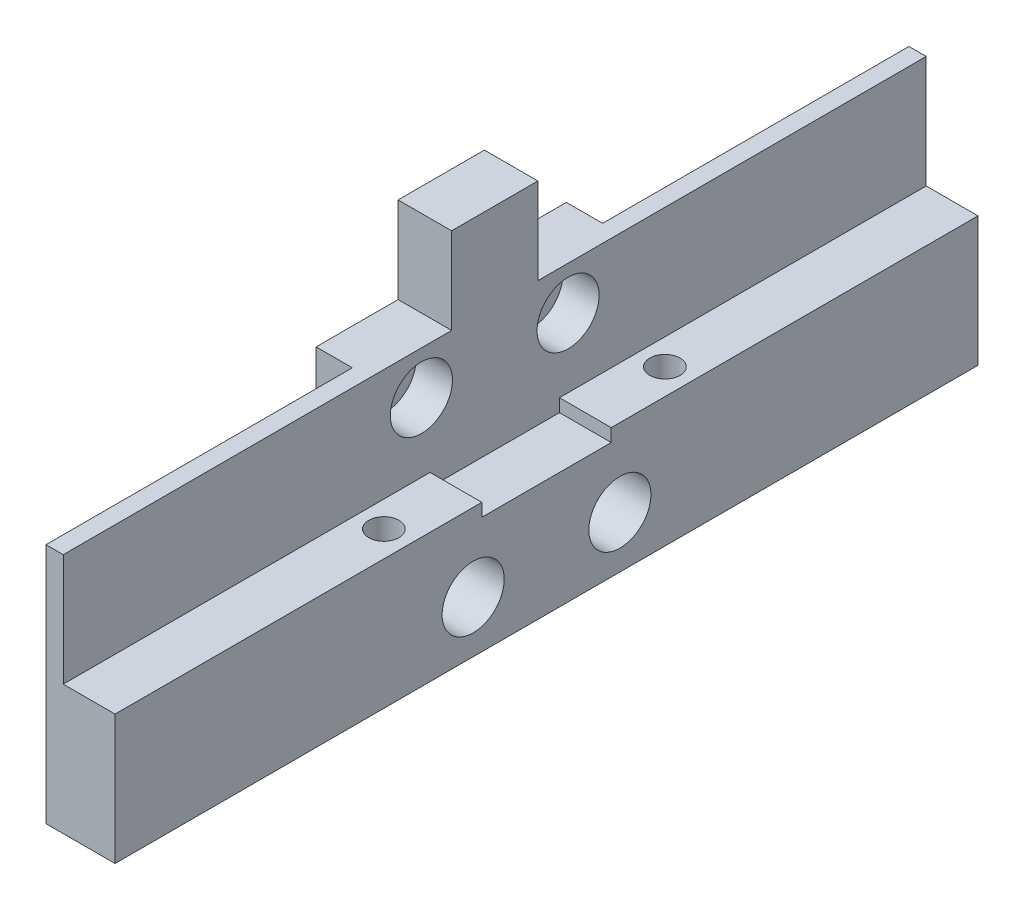
from build123d import *

# Parameters (mm, degrees)
SKETCH1_W               = 100
SKETCH1_H               = 26
BOSS_EXTRUDE1_DEPTH     = 2
BOSS_EXTRUDE2_DEPTH     = 100
SKETCH3_W               = 25
SKETCH3_H               = 28
BOSS_EXTRUDE3_DEPTH     = 4
SKETCH4_R               = 2.1
CUT_EXTRUDE1_DEPTH      = 106.39449701
SKETCH5_W               = 120
SKETCH5_H               = 46
SKETCH5_W_2             = 100
SKETCH5_H_2             = 26
CUT_EXTRUDE2_DEPTH      = 105.537074763
CUT_EXTRUDE2_DEPTH_BACK = 105.537074763
SKETCH6_W               = 100
SKETCH6_H               = 26
SKETCH6_R               = 3.6
BOSS_EXTRUDE4_DEPTH     = 4.2
SKETCH8_W               = 100
SKETCH8_H               = 4
BOSS_EXTRUDE5_DEPTH     = 6
SKETCH9_W               = 100
SKETCH9_H               = 4
BOSS_EXTRUDE6_DEPTH     = 10.2
SKETCH10_W              = 4
SKETCH10_H              = 37.5
CUT_EXTRUDE3_DEPTH      = 106.682732743
SKETCH11_W              = 4
SKETCH11_H              = 25
CUT_EXTRUDE4_DEPTH      = 107.737247482
SKETCH13_W              = 10
SKETCH13_H              = 10
BOSS_EXTRUDE7_DEPTH     = 6.2
SKETCH14_W              = 4.2
SKETCH14_H              = 35.5
CUT_EXTRUDE5_DEPTH      = 107.737247482
SKETCH15_R              = 3.6
BOSS_EXTRUDE8_DEPTH     = 6
SKETCH17_R              = 1.75
CUT_EXTRUDE7_DEPTH      = 105.984951303
MOVE_FACE2_BY           = 2


with BuildPart() as part:
    # Sketch1 → Boss-Extrude1 (new body)
    with BuildSketch(Plane(origin=(0, 0, 0), x_dir=(0, 0, -1), z_dir=(1, 0, 0))):
        with Locations((50, 13)):
            Rectangle(SKETCH1_W, SKETCH1_H)
    extrude(amount=BOSS_EXTRUDE1_DEPTH)

    # Sketch2 → Boss-Extrude2 (add)
    with BuildSketch(Plane.XY):
        Polygon((2, 26), (2, 28), (-12, 28), (-12, 24), (-10, 24), (-10, 26), align=None)
    extrude(amount=-BOSS_EXTRUDE2_DEPTH)

    # Sketch3 → Boss-Extrude3 (add)
    with BuildSketch(Plane(origin=(2, 0, 0), x_dir=(0, 0, -1), z_dir=(1, 0, 0))):
        with Locations((50, 14)):
            Rectangle(SKETCH3_W, SKETCH3_H)
    extrude(amount=BOSS_EXTRUDE3_DEPTH)

    # Sketch4 → Cut-Extrude1 (cut, through all)
    with BuildSketch(Plane(origin=(6, 0, 0), x_dir=(0, 0, -1), z_dir=(1, 0, 0))):
        with Locations((41.5, 21)):
            Circle(SKETCH4_R)
        with Locations((58.5, 21)):
            Circle(SKETCH4_R)
        with Locations((58.5, 4)):
            Circle(SKETCH4_R)
        with Locations((41.5, 4)):
            Circle(SKETCH4_R)
    extrude(amount=-CUT_EXTRUDE1_DEPTH, mode=Mode.SUBTRACT)


with BuildPart() as body_2:
    # Mirror1: mirrored copy
    add(part.part.mirror(Plane(origin=(6, 0, 0), x_dir=(0, 0, 1), z_dir=(1, 0, 0))))

    # Sketch5 → Cut-Extrude2 (cut, two sides)
    with BuildSketch(Plane(origin=(12, 0, 0), x_dir=(0, 0, -1), z_dir=(1, 0, 0))) as cut_extrude2_sk:
        with Locations((50, 13)):
            Rectangle(SKETCH5_W, SKETCH5_H)
        with Locations((50, 13)):
            Rectangle(SKETCH5_W_2, SKETCH5_H_2, mode=Mode.SUBTRACT)
    extrude(amount=CUT_EXTRUDE2_DEPTH, mode=Mode.SUBTRACT)
    extrude(cut_extrude2_sk.sketch, amount=-CUT_EXTRUDE2_DEPTH_BACK, mode=Mode.SUBTRACT)


with BuildPart() as body_2_2:
    # of the pieces the cut leaves, the one that is kept (cut_extrude2_keep)
    add(body_2.part.solids().sort_by_distance((12, 0, 0))[0])

    # Sketch6 → Boss-Extrude4 (add)
    with BuildSketch(Plane(origin=(12, 0, 0), x_dir=(0, 0, -1), z_dir=(1, 0, 0))):
        with Locations((50, 13)):
            Rectangle(SKETCH6_W, SKETCH6_H)
        with Locations((41.5, 21)):
            Circle(SKETCH6_R, mode=Mode.SUBTRACT)
        with Locations((58.5, 21)):
            Circle(SKETCH6_R, mode=Mode.SUBTRACT)
        with Locations((58.5, 4)):
            Circle(SKETCH6_R, mode=Mode.SUBTRACT)
        with Locations((41.5, 4)):
            Circle(SKETCH6_R, mode=Mode.SUBTRACT)
    extrude(amount=BOSS_EXTRUDE4_DEPTH)



with BuildPart() as body_2_3:
    # Sketch8 → Boss-Extrude5 (new body)
    with BuildSketch(Plane(origin=(16.2, 0, 0), x_dir=(0, 0, -1), z_dir=(1, 0, 0))):
        with Locations((50, -2)):
            Rectangle(SKETCH8_W, SKETCH8_H)
    extrude(amount=BOSS_EXTRUDE5_DEPTH)


with BuildPart() as body_2_2_1:
    add(body_2_2.part)

    add(body_2_3.part)  # Boss-Extrude6 merges body 2 3
    # Sketch9 → Boss-Extrude6 (add)
    with BuildSketch(Plane.ZY.offset(-16.2)):
        with Locations((-50, -2)):
            Rectangle(SKETCH9_W, SKETCH9_H)
    extrude(amount=BOSS_EXTRUDE6_DEPTH)

    # Sketch10 → Cut-Extrude3 (cut, through all)
    with BuildSketch(Plane(origin=(0, 0, 0), x_dir=(1, 0, 0), z_dir=(0, 1, 0))):
        with Locations((8, 81.25)):
            Rectangle(SKETCH10_W, SKETCH10_H)
        with Locations((8, 18.75)):
            Rectangle(SKETCH10_W, SKETCH10_H)
    extrude(amount=-CUT_EXTRUDE3_DEPTH, mode=Mode.SUBTRACT)

    # Sketch11 → Cut-Extrude4 (cut, through all)
    with BuildSketch(Plane(origin=(0, 26, 0), x_dir=(1, 0, 0), z_dir=(0, 1, 0))):
        with Locations((8, 50)):
            Rectangle(SKETCH11_W, SKETCH11_H)
    extrude(amount=-CUT_EXTRUDE4_DEPTH, mode=Mode.SUBTRACT)

    # Sketch13 → Boss-Extrude7 (add)
    with BuildSketch(Plane.ZY.offset(-10)):
        with Locations((-50, 31)):
            Rectangle(SKETCH13_W, SKETCH13_H)
    extrude(amount=-BOSS_EXTRUDE7_DEPTH)

    # Sketch14 → Cut-Extrude5 (cut, through all)
    with BuildSketch(Plane(origin=(0, 26, 0), x_dir=(1, 0, 0), z_dir=(0, 1, 0))):
        with Locations((12.1, 17.75)):
            Rectangle(SKETCH14_W, SKETCH14_H)
        with Locations((12.1, 82.25)):
            Rectangle(SKETCH14_W, SKETCH14_H)
    extrude(amount=-CUT_EXTRUDE5_DEPTH, mode=Mode.SUBTRACT)

    # Sketch15 → Boss-Extrude8 (add)
    with BuildSketch(Plane(origin=(22.2, 0, 0), x_dir=(0, 0, -1), z_dir=(1, 0, 0))):
        Polygon((0, 0), (100, 0), (100, 13), (57.5, 13), (57.5, 11.5), (42.5, 11.5), (42.5, 13), (0, 13), align=None)
        with Locations((41.5, 4)):
            Circle(SKETCH15_R, mode=Mode.SUBTRACT)
        with Locations((58.5, 4)):
            Circle(SKETCH15_R, mode=Mode.SUBTRACT)
    extrude(amount=-BOSS_EXTRUDE8_DEPTH)

    # Sketch17 → Cut-Extrude7 (cut, through all)
    with BuildSketch(Plane(origin=(0, 13, 0), x_dir=(1, 0, 0), z_dir=(0, 1, 0))):
        with Locations(Location((19.2, 34.15, 0), (0, 0, 270))):
            Circle(SKETCH17_R)
        with Locations(Location((19.2, 66.71679058, 0), (0, 0, 270))):
            Circle(SKETCH17_R)
    extrude(amount=-CUT_EXTRUDE7_DEPTH, mode=Mode.SUBTRACT)

    # Move Face2: a face moved inward by 2.0
    extrude(body_2_2_1.faces().sort_by_distance((17.355486439, -4, -49.990760145))[0], amount=MOVE_FACE2_BY, dir=(0, 1, 0), mode=Mode.SUBTRACT)


solid = body_2_2_1.part
